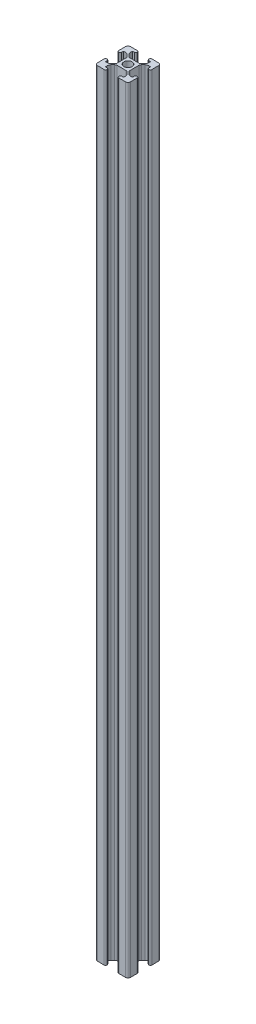
from build123d import *

# Parameters (mm, degrees)
SKETCH2_R           = 2.5
BOSS_EXTRUDE1_DEPTH = 470


with BuildPart() as part:
    # Sketch2 → Boss-Extrude1 (new body)
    with BuildSketch(Plane(origin=(0, 0, 0), x_dir=(1, 0, 0), z_dir=(0, 1, 0))):
        with BuildLine():
            Line((-5.4, 4.869669914), (-4.339339828, 3.809009742))
            ThreePointArc((-4.339339828, 3.809009742), (-4.014180701, 3.322374719), (-3.9, 2.748349571))
            Line((-3.9, 2.748349571), (-3.9, -2.748349571))
            ThreePointArc((-3.9, -2.748349571), (-4.014180701, -3.322374719), (-4.339339828, -3.809009742))
            Line((-4.339339828, -3.809009742), (-5.4, -4.869669914))
            ThreePointArc((-5.4, -4.869669914), (-6.246412561, -5.337861749), (-7.2, -5.5))
            Line((-7.2, -5.5), (-8.2, -5.5))
            Line((-8.2, -5.5), (-8.2, -4.4))
            ThreePointArc((-8.2, -4.4), (-8.434314575, -3.834314575), (-9, -3.6))
            Line((-9, -3.6), (-9.2, -3.6))
            ThreePointArc((-9.2, -3.6), (-9.765685425, -3.834314575), (-10, -4.4))
            Line((-10, -4.4), (-10, -8.5))
            ThreePointArc((-10, -8.5), (-9.560660172, -9.560660172), (-8.5, -10))
            Line((-8.5, -10), (-4.4, -10))
            ThreePointArc((-4.4, -10), (-3.834314575, -9.765685425), (-3.6, -9.2))
            Line((-3.6, -9.2), (-3.6, -9))
            ThreePointArc((-3.6, -9), (-3.834314575, -8.434314575), (-4.4, -8.2))
            Line((-4.4, -8.2), (-5.5, -8.2))
            Line((-5.5, -8.2), (-5.5, -7.2))
            ThreePointArc((-5.5, -7.2), (-5.337861749, -6.246412561), (-4.869669914, -5.4))
            Line((-4.869669914, -5.4), (-3.809009742, -4.339339828))
            ThreePointArc((-3.809009742, -4.339339828), (-3.322374719, -4.014180701), (-2.748349571, -3.9))
            Line((-2.748349571, -3.9), (2.748349571, -3.9))
            ThreePointArc((2.748349571, -3.9), (3.322374719, -4.014180701), (3.809009742, -4.339339828))
            Line((3.809009742, -4.339339828), (4.869669914, -5.4))
            ThreePointArc((4.869669914, -5.4), (5.337861749, -6.246412561), (5.5, -7.2))
            Line((5.5, -7.2), (5.5, -8.2))
            Line((5.5, -8.2), (4.4, -8.2))
            ThreePointArc((4.4, -8.2), (3.834314575, -8.434314575), (3.6, -9))
            Line((3.6, -9), (3.6, -9.2))
            ThreePointArc((3.6, -9.2), (3.834314575, -9.765685425), (4.4, -10))
            Line((4.4, -10), (8.5, -10))
            ThreePointArc((8.5, -10), (9.560660172, -9.560660172), (10, -8.5))
            Line((10, -8.5), (10, -4.4))
            ThreePointArc((10, -4.4), (9.765685425, -3.834314575), (9.2, -3.6))
            Line((9.2, -3.6), (9, -3.6))
            ThreePointArc((9, -3.6), (8.434314575, -3.834314575), (8.2, -4.4))
            Line((8.2, -4.4), (8.2, -5.5))
            Line((8.2, -5.5), (7.2, -5.5))
            ThreePointArc((7.2, -5.5), (6.246412561, -5.337861749), (5.4, -4.869669914))
            Line((5.4, -4.869669914), (4.339339828, -3.809009742))
            ThreePointArc((4.339339828, -3.809009742), (4.014180701, -3.322374719), (3.9, -2.748349571))
            Line((3.9, -2.748349571), (3.9, 2.748349571))
            ThreePointArc((3.9, 2.748349571), (4.014180701, 3.322374719), (4.339339828, 3.809009742))
            Line((4.339339828, 3.809009742), (5.4, 4.869669914))
            ThreePointArc((5.4, 4.869669914), (6.246412561, 5.337861749), (7.2, 5.5))
            Line((7.2, 5.5), (8.2, 5.5))
            Line((8.2, 5.5), (8.2, 4.4))
            ThreePointArc((8.2, 4.4), (8.434314575, 3.834314575), (9, 3.6))
            Line((9, 3.6), (9.2, 3.6))
            ThreePointArc((9.2, 3.6), (9.765685425, 3.834314575), (10, 4.4))
            Line((10, 4.4), (10, 8.5))
            ThreePointArc((10, 8.5), (9.560660172, 9.560660172), (8.5, 10))
            Line((8.5, 10), (4.4, 10))
            ThreePointArc((4.4, 10), (3.834314575, 9.765685425), (3.6, 9.2))
            Line((3.6, 9.2), (3.6, 9))
            ThreePointArc((3.6, 9), (3.834314575, 8.434314575), (4.4, 8.2))
            Line((4.4, 8.2), (5.5, 8.2))
            Line((5.5, 8.2), (5.5, 7.2))
            ThreePointArc((5.5, 7.2), (5.337861749, 6.246412561), (4.869669914, 5.4))
            Line((4.869669914, 5.4), (3.809009742, 4.339339828))
            ThreePointArc((3.809009742, 4.339339828), (3.322374719, 4.014180701), (2.748349571, 3.9))
            Line((2.748349571, 3.9), (-2.748349571, 3.9))
            ThreePointArc((-2.748349571, 3.9), (-3.322374719, 4.014180701), (-3.809009742, 4.339339828))
            Line((-3.809009742, 4.339339828), (-4.869669914, 5.4))
            ThreePointArc((-4.869669914, 5.4), (-5.337861749, 6.246412561), (-5.5, 7.2))
            Line((-5.5, 7.2), (-5.5, 8.2))
            Line((-5.5, 8.2), (-4.4, 8.2))
            ThreePointArc((-4.4, 8.2), (-3.834314575, 8.434314575), (-3.6, 9))
            Line((-3.6, 9), (-3.6, 9.2))
            ThreePointArc((-3.6, 9.2), (-3.834314575, 9.765685425), (-4.4, 10))
            Line((-4.4, 10), (-8.5, 10))
            ThreePointArc((-8.5, 10), (-9.560660172, 9.560660172), (-10, 8.5))
            Line((-10, 8.5), (-10, 4.4))
            ThreePointArc((-10, 4.4), (-9.765685425, 3.834314575), (-9.2, 3.6))
            Line((-9.2, 3.6), (-9, 3.6))
            ThreePointArc((-9, 3.6), (-8.434314575, 3.834314575), (-8.2, 4.4))
            Line((-8.2, 4.4), (-8.2, 5.5))
            Line((-8.2, 5.5), (-7.2, 5.5))
            ThreePointArc((-7.2, 5.5), (-6.246412561, 5.337861749), (-5.4, 4.869669914))
        make_face()
        Circle(SKETCH2_R, mode=Mode.SUBTRACT)
    extrude(amount=BOSS_EXTRUDE1_DEPTH)


solid = part.part
